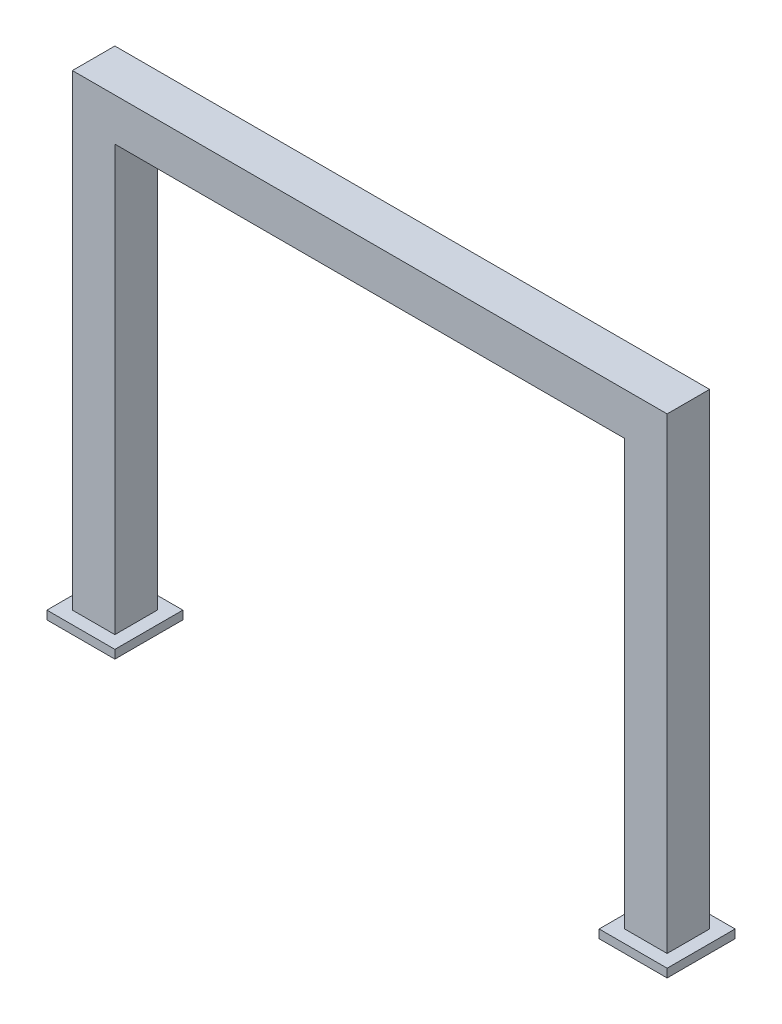
from build123d import *

# Parameters (mm, degrees)
EXTRUDE_1_DEPTH = 25
SKETCH_2_W      = 80
SKETCH_2_H      = 80
EXTRUDE_2_DEPTH = 10


with BuildPart() as part:
    # 草图1 → 凸台-拉伸1 (new body, symmetric)
    with BuildSketch(Plane.XY):
        Polygon((-350, 0), (-350, 550), (350, 550), (350, 0), (300, 0), (300, 500), (-300, 500), (-300, 0), align=None)
    extrude(amount=EXTRUDE_1_DEPTH, both=True)

    # 草图2 → 凸台-拉伸2 (add)
    with BuildSketch(Plane.XZ):
        with Locations((-325, 0)):
            Rectangle(SKETCH_2_W, SKETCH_2_H)
        with Locations((325, 0)):
            Rectangle(SKETCH_2_W, SKETCH_2_H)
    extrude(amount=EXTRUDE_2_DEPTH)


solid = part.part
